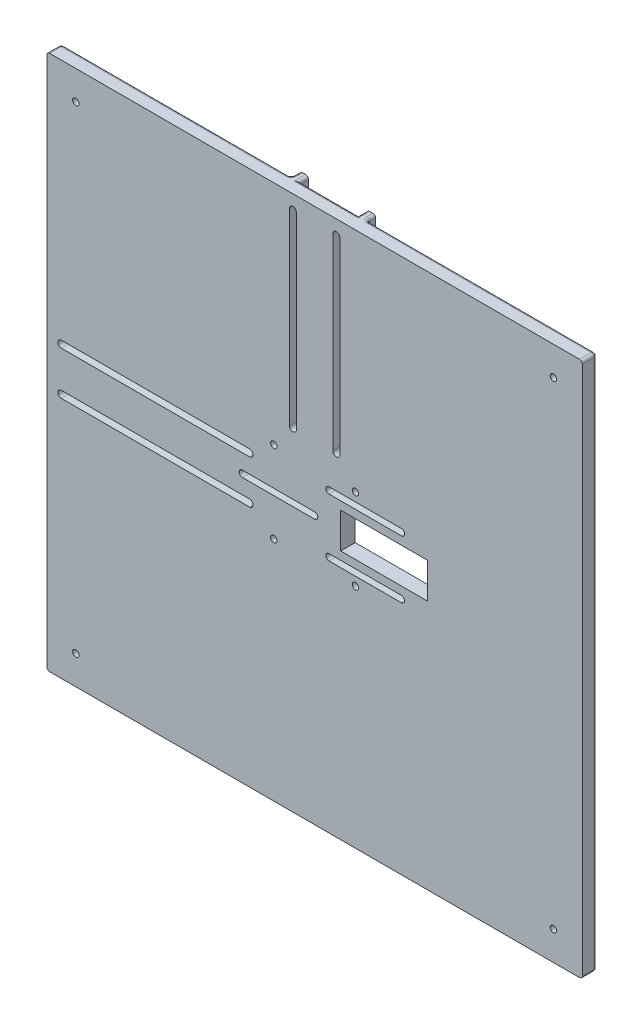
from build123d import *

# Parameters (mm, degrees)
ESQUISSE1_W              = 185
ESQUISSE1_H              = 185
BOSS_EXTRU_1_DEPTH       = 5
ESQUISSE2_W              = 70
ESQUISSE2_H              = 3
ESQUISSE2_W_2            = 3
ESQUISSE2_H_2            = 70
BOSS_EXTRU_2_DEPTH       = 3
CONG_1_R                 = 1
ENL_V_MAT_EXTRU_1_REACH  = 7
ESQUISSE4_R              = 1.1
ENL_V_MAT_EXTRU_2_DEPTH  = 6
ENL_V_MAT_EXTRU_3_REACH  = 7
ENL_V_MAT_EXTRU_5_REACH  = 10
ENL_V_MAT_EXTRU_7_REACH  = 7
ESQUISSE11_W             = 30
ESQUISSE11_H             = 12.2
ESQUISSE12_W             = 31
ESQUISSE12_H             = 4.3
ENL_V_MAT_EXTRU_9_DEPTH  = 2
CONG_2_R                 = 0.5
ENL_V_MAT_EXTRU_10_DEPTH = 3


with BuildPart() as part:
    # Esquisse1 → Boss.-Extru.1 (new body)
    with BuildSketch(Plane.XY):
        Rectangle(ESQUISSE1_W, ESQUISSE1_H)
    extrude(amount=BOSS_EXTRU_1_DEPTH)

    # Esquisse2 → Boss.-Extru.2 (add)
    with BuildSketch(Plane(origin=(0, 0, 0), x_dir=(-1, 0, 0), z_dir=(0, 0, -1))):
        with Locations((57.5, 11.6)):
            Rectangle(ESQUISSE2_W, ESQUISSE2_H)
        with Locations((57.5, -11.6)):
            Rectangle(ESQUISSE2_W, ESQUISSE2_H)
        with Locations((11.6, 57.5)):
            Rectangle(ESQUISSE2_W_2, ESQUISSE2_H_2)
        with Locations((-11.6, 57.5)):
            Rectangle(ESQUISSE2_W_2, ESQUISSE2_H_2)
    extrude(amount=BOSS_EXTRU_2_DEPTH)

    # Congé1
    cong_1_edges = [part.edges().sort_by_distance(p)[0] for p in [
        (0, 92.5, 0),
        (11.6, 22.5, 0),
        (13.1, 22.5, -1.5),
        (10.1, 92.5, -1.5),
        (13.1, 57.5, 0),
        (13.1, 92.5, -1.5),
        (-92.5, 0, 0),
        (-57.5, 13.1, 0),
        (-92.5, 13.1, -1.5),
        (-22.5, 11.6, 0),
        (-22.5, 13.1, -1.5),
        (-92.5, 10.1, -1.5),
        (-92.5, -52.8, 0),
        (-92.5, -13.1, -1.5),
        (-92.5, -10.1, -1.5),
        (-22.5, -11.6, 0),
        (-57.5, -13.1, 0),
        (-22.5, -13.1, -1.5),
        (-52.8, 92.5, 0),
        (-11.6, 22.5, 0),
        (-13.1, 57.5, 0),
        (-13.1, 22.5, -1.5),
        (-13.1, 92.5, -1.5),
        (-10.1, 92.5, -1.5),
        (52.8, 92.5, 0),
        (92.5, 0, 0),
        (0, -92.5, 0),
        (-92.5, 52.8, 0),
        (-92.5, 92.5, 2.5),
        (92.5, 92.5, 2.5),
        (92.5, -92.5, 2.5),
        (-92.5, -92.5, 2.5),
    ]]
    fillet(cong_1_edges, radius=CONG_1_R)

    # Esquisse4 → Enlèv. mat.-Extru.1 (cut, up to next)
    with BuildSketch(Plane(origin=(0, 0, 0), x_dir=(-1, 0, 0), z_dir=(0, 0, -1)), mode=Mode.PRIVATE) as enl_v_mat_extru_1_sk1:
        with Locations((-14.1, 14.1)):
            Circle(ESQUISSE4_R)
    enl_v_mat_extru_1_tool1 = extrude(enl_v_mat_extru_1_sk1.sketch, amount=-ENL_V_MAT_EXTRU_1_REACH, mode=Mode.PRIVATE) & part.part
    add(enl_v_mat_extru_1_tool1.solids().sort_by_distance((14.1, 14.1, 0))[0], mode=Mode.SUBTRACT)
    # Esquisse4 → Enlèv. mat.-Extru.1 (cut, up to next)
    with BuildSketch(Plane(origin=(0, 0, 0), x_dir=(-1, 0, 0), z_dir=(0, 0, -1)), mode=Mode.PRIVATE) as enl_v_mat_extru_1_sk2:
        with Locations((14.1, 14.1)):
            Circle(ESQUISSE4_R)
    enl_v_mat_extru_1_tool2 = extrude(enl_v_mat_extru_1_sk2.sketch, amount=-ENL_V_MAT_EXTRU_1_REACH, mode=Mode.PRIVATE) & part.part
    add(enl_v_mat_extru_1_tool2.solids().sort_by_distance((-14.1, 14.1, 0))[0], mode=Mode.SUBTRACT)
    # Esquisse4 → Enlèv. mat.-Extru.1 (cut, up to next)
    with BuildSketch(Plane(origin=(0, 0, 0), x_dir=(-1, 0, 0), z_dir=(0, 0, -1)), mode=Mode.PRIVATE) as enl_v_mat_extru_1_sk3:
        with Locations((14.1, -14.1)):
            Circle(ESQUISSE4_R)
    enl_v_mat_extru_1_tool3 = extrude(enl_v_mat_extru_1_sk3.sketch, amount=-ENL_V_MAT_EXTRU_1_REACH, mode=Mode.PRIVATE) & part.part
    add(enl_v_mat_extru_1_tool3.solids().sort_by_distance((-14.1, -14.1, 0))[0], mode=Mode.SUBTRACT)
    # Esquisse4 → Enlèv. mat.-Extru.1 (cut, up to next)
    with BuildSketch(Plane(origin=(0, 0, 0), x_dir=(-1, 0, 0), z_dir=(0, 0, -1)), mode=Mode.PRIVATE) as enl_v_mat_extru_1_sk4:
        with Locations((-14.1, -14.1)):
            Circle(ESQUISSE4_R)
    enl_v_mat_extru_1_tool4 = extrude(enl_v_mat_extru_1_sk4.sketch, amount=-ENL_V_MAT_EXTRU_1_REACH, mode=Mode.PRIVATE) & part.part
    add(enl_v_mat_extru_1_tool4.solids().sort_by_distance((14.1, -14.1, 0))[0], mode=Mode.SUBTRACT)
    # Esquisse4 → Enlèv. mat.-Extru.1 (cut, up to next)
    with BuildSketch(Plane(origin=(0, 0, 0), x_dir=(-1, 0, 0), z_dir=(0, 0, -1)), mode=Mode.PRIVATE) as enl_v_mat_extru_1_sk5:
        with Locations((-82.5, -82.5)):
            Circle(ESQUISSE4_R)
    enl_v_mat_extru_1_tool5 = extrude(enl_v_mat_extru_1_sk5.sketch, amount=-ENL_V_MAT_EXTRU_1_REACH, mode=Mode.PRIVATE) & part.part
    add(enl_v_mat_extru_1_tool5.solids().sort_by_distance((82.5, -82.5, 0))[0], mode=Mode.SUBTRACT)
    # Esquisse4 → Enlèv. mat.-Extru.1 (cut, up to next)
    with BuildSketch(Plane(origin=(0, 0, 0), x_dir=(-1, 0, 0), z_dir=(0, 0, -1)), mode=Mode.PRIVATE) as enl_v_mat_extru_1_sk6:
        with Locations((-82.5, 82.5)):
            Circle(ESQUISSE4_R)
    enl_v_mat_extru_1_tool6 = extrude(enl_v_mat_extru_1_sk6.sketch, amount=-ENL_V_MAT_EXTRU_1_REACH, mode=Mode.PRIVATE) & part.part
    add(enl_v_mat_extru_1_tool6.solids().sort_by_distance((82.5, 82.5, 0))[0], mode=Mode.SUBTRACT)
    # Esquisse4 → Enlèv. mat.-Extru.1 (cut, up to next)
    with BuildSketch(Plane(origin=(0, 0, 0), x_dir=(-1, 0, 0), z_dir=(0, 0, -1)), mode=Mode.PRIVATE) as enl_v_mat_extru_1_sk7:
        with Locations((82.5, -82.5)):
            Circle(ESQUISSE4_R)
    enl_v_mat_extru_1_tool7 = extrude(enl_v_mat_extru_1_sk7.sketch, amount=-ENL_V_MAT_EXTRU_1_REACH, mode=Mode.PRIVATE) & part.part
    add(enl_v_mat_extru_1_tool7.solids().sort_by_distance((-82.5, -82.5, 0))[0], mode=Mode.SUBTRACT)
    # Esquisse4 → Enlèv. mat.-Extru.1 (cut, up to next)
    with BuildSketch(Plane(origin=(0, 0, 0), x_dir=(-1, 0, 0), z_dir=(0, 0, -1)), mode=Mode.PRIVATE) as enl_v_mat_extru_1_sk8:
        with Locations((82.5, 82.5)):
            Circle(ESQUISSE4_R)
    enl_v_mat_extru_1_tool8 = extrude(enl_v_mat_extru_1_sk8.sketch, amount=-ENL_V_MAT_EXTRU_1_REACH, mode=Mode.PRIVATE) & part.part
    add(enl_v_mat_extru_1_tool8.solids().sort_by_distance((-82.5, 82.5, 0))[0], mode=Mode.SUBTRACT)

    # Esquisse5 → Enlèv. mat.-Extru.2 (cut, through all)
    with BuildSketch(Plane(origin=(0, 0, 0), x_dir=(-1, 0, 0), z_dir=(0, 0, -1))):
        with BuildLine():
            Line((-6.3, 87.5), (-6.3, 22.5))
            ThreePointArc((-6.3, 22.5), (-7.5, 21.3), (-8.7, 22.5))
            Line((-8.7, 22.5), (-8.7, 87.5))
            ThreePointArc((-8.7, 87.5), (-7.5, 88.7), (-6.3, 87.5))
        make_face()
        with BuildLine():
            Line((8.7, 87.5), (8.7, 22.5))
            ThreePointArc((8.7, 22.5), (7.5, 21.3), (6.3, 22.5))
            Line((6.3, 22.5), (6.3, 87.5))
            ThreePointArc((6.3, 87.5), (7.5, 88.7), (8.7, 87.5))
        make_face()
    extrude(amount=-ENL_V_MAT_EXTRU_2_DEPTH, mode=Mode.SUBTRACT)

    # Esquisse6 → Enlèv. mat.-Extru.3 (cut, up to next)
    with BuildSketch(Plane(origin=(0, 0, 0), x_dir=(-1, 0, 0), z_dir=(0, 0, -1)), mode=Mode.PRIVATE) as enl_v_mat_extru_3_sk1:
        with BuildLine():
            Line((87.5, -8.7), (22.5, -8.7))
            ThreePointArc((22.5, -8.7), (21.3, -7.5), (22.5, -6.3))
            Line((22.5, -6.3), (87.5, -6.3))
            ThreePointArc((87.5, -6.3), (88.7, -7.5), (87.5, -8.7))
        make_face()
    enl_v_mat_extru_3_tool1 = extrude(enl_v_mat_extru_3_sk1.sketch, amount=-ENL_V_MAT_EXTRU_3_REACH, mode=Mode.PRIVATE) & part.part
    add(enl_v_mat_extru_3_tool1.solids().sort_by_distance((-55, -7.5, 0))[0], mode=Mode.SUBTRACT)
    # Esquisse6 → Enlèv. mat.-Extru.3 (cut, up to next)
    with BuildSketch(Plane(origin=(0, 0, 0), x_dir=(-1, 0, 0), z_dir=(0, 0, -1)), mode=Mode.PRIVATE) as enl_v_mat_extru_3_sk2:
        with BuildLine():
            Line((22.5, 8.7), (87.5, 8.7))
            ThreePointArc((87.5, 8.7), (88.7, 7.5), (87.5, 6.3))
            Line((87.5, 6.3), (22.5, 6.3))
            ThreePointArc((22.5, 6.3), (21.3, 7.5), (22.5, 8.7))
        make_face()
    enl_v_mat_extru_3_tool2 = extrude(enl_v_mat_extru_3_sk2.sketch, amount=-ENL_V_MAT_EXTRU_3_REACH, mode=Mode.PRIVATE) & part.part
    add(enl_v_mat_extru_3_tool2.solids().sort_by_distance((-55, 7.5, 0))[0], mode=Mode.SUBTRACT)

    # Esquisse9 → Enlèv. mat.-Extru.5 (cut, up to next)
    with BuildSketch(Plane.XY.offset(5), mode=Mode.PRIVATE) as enl_v_mat_extru_5_sk1:
        with BuildLine():
            Line((-25, 1.1), (0, 1.1))
            ThreePointArc((0, 1.1), (1.1, 0), (0, -1.1))
            Line((0, -1.1), (-25, -1.1))
            ThreePointArc((-25, -1.1), (-26.1, 0), (-25, 1.1))
        make_face()
    enl_v_mat_extru_5_tool1 = extrude(enl_v_mat_extru_5_sk1.sketch, amount=-ENL_V_MAT_EXTRU_5_REACH, mode=Mode.PRIVATE) & part.part
    add(enl_v_mat_extru_5_tool1.solids().sort_by_distance((-12.5, 0, 5))[0], mode=Mode.SUBTRACT)
    # Esquisse9 → Enlèv. mat.-Extru.5 (cut, up to next)
    with BuildSketch(Plane.XY.offset(5), mode=Mode.PRIVATE) as enl_v_mat_extru_5_sk2:
        with BuildLine():
            Line((5, 11.1), (30, 11.1))
            ThreePointArc((30, 11.1), (31.1, 10), (30, 8.9))
            Line((30, 8.9), (5, 8.9))
            ThreePointArc((5, 8.9), (3.9, 10), (5, 11.1))
        make_face()
    enl_v_mat_extru_5_tool2 = extrude(enl_v_mat_extru_5_sk2.sketch, amount=-ENL_V_MAT_EXTRU_5_REACH, mode=Mode.PRIVATE) & part.part
    add(enl_v_mat_extru_5_tool2.solids().sort_by_distance((17.5, 10, 5))[0], mode=Mode.SUBTRACT)
    # Esquisse9 → Enlèv. mat.-Extru.5 (cut, up to next)
    with BuildSketch(Plane.XY.offset(5), mode=Mode.PRIVATE) as enl_v_mat_extru_5_sk3:
        with BuildLine():
            Line((5, -8.9), (30, -8.9))
            ThreePointArc((30, -8.9), (31.1, -10), (30, -11.1))
            Line((30, -11.1), (5, -11.1))
            ThreePointArc((5, -11.1), (3.9, -10), (5, -8.9))
        make_face()
    enl_v_mat_extru_5_tool3 = extrude(enl_v_mat_extru_5_sk3.sketch, amount=-ENL_V_MAT_EXTRU_5_REACH, mode=Mode.PRIVATE) & part.part
    add(enl_v_mat_extru_5_tool3.solids().sort_by_distance((17.5, -10, 5))[0], mode=Mode.SUBTRACT)

    # Esquisse11 → Enlèv. mat.-Extru.7 (cut, up to next)
    with BuildSketch(Plane(origin=(0, 0, 0), x_dir=(-1, 0, 0), z_dir=(0, 0, -1)), mode=Mode.PRIVATE) as enl_v_mat_extru_7_sk1:
        with Locations((-24, 0)):
            Rectangle(ESQUISSE11_W, ESQUISSE11_H)
    enl_v_mat_extru_7_tool1 = extrude(enl_v_mat_extru_7_sk1.sketch, amount=-ENL_V_MAT_EXTRU_7_REACH, mode=Mode.PRIVATE) & part.part
    add(enl_v_mat_extru_7_tool1.solids().sort_by_distance((24, 0, 0))[0], mode=Mode.SUBTRACT)

    # Esquisse12 → Enlèv. mat.-Extru.9 (cut)
    with BuildSketch(Plane(origin=(0, 0, 0), x_dir=(-1, 0, 0), z_dir=(0, 0, -1))):
        with Locations((-17.5, 9.95)):
            Rectangle(ESQUISSE12_W, ESQUISSE12_H)
        with Locations((-17.5, -10.05)):
            Rectangle(ESQUISSE12_W, ESQUISSE12_H)
        with Locations((12.5, -0.05)):
            Rectangle(ESQUISSE12_W, ESQUISSE12_H)
    extrude(amount=-ENL_V_MAT_EXTRU_9_DEPTH, mode=Mode.SUBTRACT)

    # Congé2
    cong_2_edges = [part.edges().sort_by_distance(p)[0] for p in [
        (33, 7.8, 1),
        (33, 12.1, 1),
        (2, 12.1, 1),
        (33, -12.2, 1),
        (33, -7.9, 1),
        (2, -7.9, 1),
        (2, -12.2, 1),
        (3, -2.2, 1),
        (3, 2.1, 1),
        (-28, 2.1, 1),
        (-28, -2.2, 1),
    ]]
    fillet(cong_2_edges, radius=CONG_2_R)

    # Esquisse13 → Enlèv. mat.-Extru.10 (cut)
    with BuildSketch(Plane(origin=(0, 0, 0), x_dir=(-1, 0, 0), z_dir=(0, 0, -1))):
        Polygon((-80, -82.5), (-81.25, -80.334936491), (-83.75, -80.334936491), (-85, -82.5), (-83.75, -84.665063509), (-81.25, -84.665063509), align=None)
        Polygon((83.75, -84.665063509), (85, -82.5), (83.75, -80.334936491), (81.25, -80.334936491), (80, -82.5), (81.25, -84.665063509), align=None)
        Polygon((85, 82.5), (83.75, 84.665063509), (81.25, 84.665063509), (80, 82.5), (81.25, 80.334936491), (83.75, 80.334936491), align=None)
        Polygon((-80, 82.5), (-81.25, 84.665063509), (-83.75, 84.665063509), (-85, 82.5), (-83.75, 80.334936491), (-81.25, 80.334936491), align=None)
    extrude(amount=-ENL_V_MAT_EXTRU_10_DEPTH, mode=Mode.SUBTRACT)


solid = part.part
